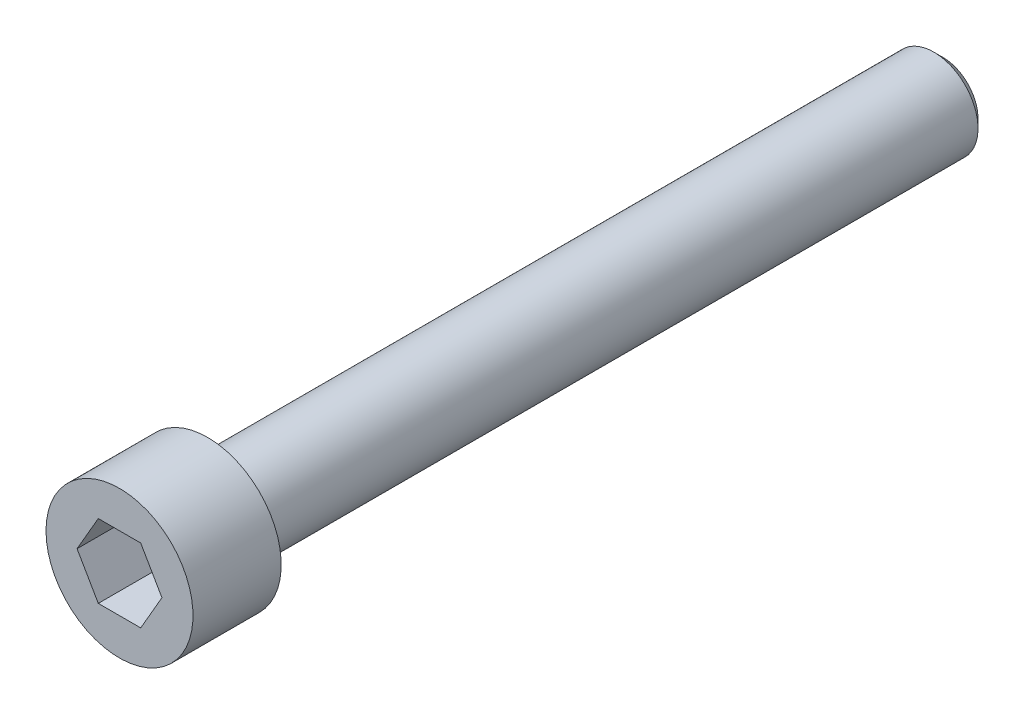
from build123d import *

# Parameters (mm, degrees)
CUT_EXTRUDE_1_DEPTH = 2
FILLET_1_R          = 0.3
CHAMFER_1_SIZE      = 0.3


with BuildPart() as part:
    # Эскиз1 → Повернуть1 (revolve)
    with BuildSketch(Plane(origin=(0, 0, 0), x_dir=(0, 0, -1), z_dir=(1, 0, 0))):
        Polygon((0, 0), (0, 2.5), (3, 2.5), (3, 1.5), (28, 1.5), (28, 0), align=None)
    revolve(axis=Axis((0, 0, 0), (0, 0, 1)))

    # Эскиз2 → Вырез-Вытянуть1 (cut)
    with BuildSketch(Plane.XY):
        Polygon((1.443375673, 0), (0.721687836, 1.25), (-0.721687836, 1.25), (-1.443375673, 0), (-0.721687836, -1.25), (0.721687836, -1.25), align=None)
    extrude(amount=-CUT_EXTRUDE_1_DEPTH, mode=Mode.SUBTRACT)

    # Скругление1
    fillet_1_edges = [part.edges().sort_by_distance(p)[0] for p in [
        (0, -1.5, -3),
    ]]
    fillet(fillet_1_edges, radius=FILLET_1_R)

    # Фаска1
    chamfer_1_edges = [part.edges().sort_by_distance(p)[0] for p in [
        (0, -1.5, -28),
    ]]
    chamfer(chamfer_1_edges, length=CHAMFER_1_SIZE)


solid = part.part
